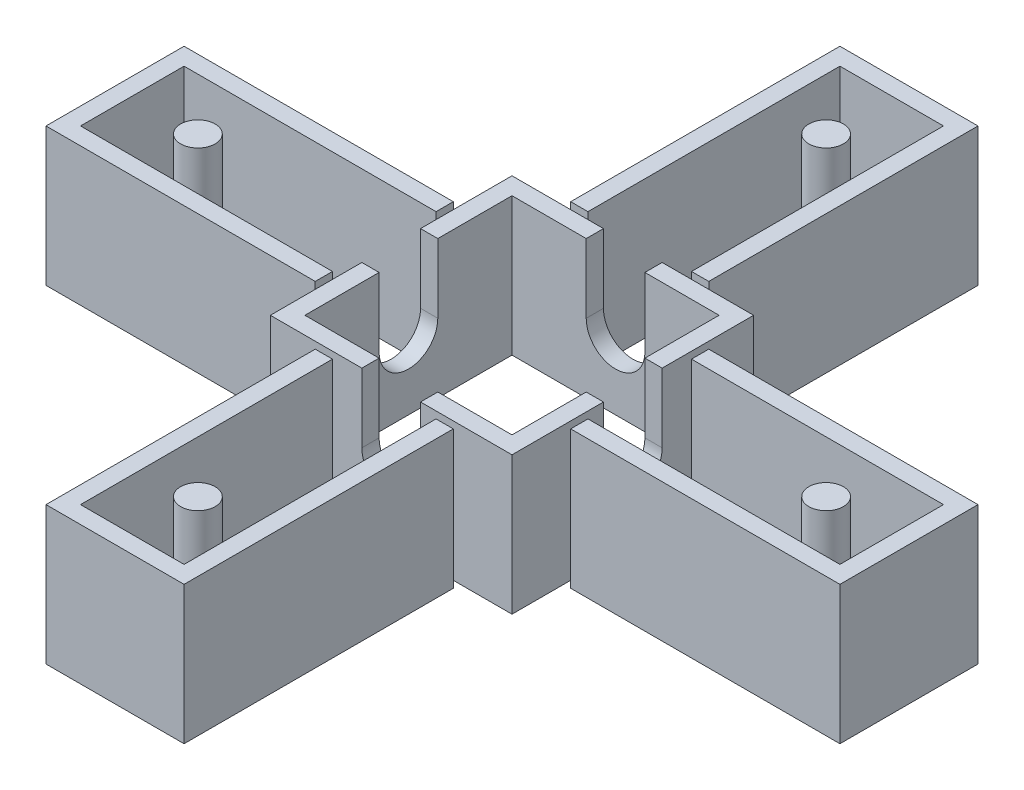
from build123d import *

# Parameters (mm, degrees)
SKETCH1_W           = 35
SKETCH1_H           = 35
SKETCH1_W_2         = 30
SKETCH1_H_2         = 30
BOSS_EXTRUDE1_DEPTH = 20
CUT_EXTRUDE1_DEPTH  = 2.5
CIRPATTERN1_COUNT   = 4
BOSS_EXTRUDE2_DEPTH = 20
SKETCH6_W           = 5
SKETCH6_H           = 3
BOSS_EXTRUDE3_DEPTH = 12
SKETCH7_R           = 2.5
BOSS_EXTRUDE4_DEPTH = 17
CIRPATTERN6_COUNT   = 4
SKETCH8_W           = 2.5
SKETCH8_H           = 1
SKETCH8_W_2         = 1
SKETCH8_H_2         = 2.5
CUT_EXTRUDE4_DEPTH  = 21


with BuildPart() as part:
    # Sketch1 → Boss-Extrude1 (new body)
    with BuildSketch(Plane(origin=(0, 0, 0), x_dir=(1, 0, 0), z_dir=(0, 1, 0))):
        Rectangle(SKETCH1_W, SKETCH1_H)
        Rectangle(SKETCH1_W_2, SKETCH1_H_2, mode=Mode.SUBTRACT)
    extrude(amount=BOSS_EXTRUDE1_DEPTH)

    # Sketch2 → Cut-Extrude1 (cut)
    with BuildSketch(Plane.ZY.offset(17.5)):
        with BuildLine():
            Line((-4.25, 10), (-4.25, 20))
            Line((-4.25, 20), (4.25, 20))
            Line((4.25, 20), (4.25, 10))
            ThreePointArc((4.25, 10), (0, 5.75), (-4.25, 10))
        make_face()
    cut_extrude1 = extrude(amount=-CUT_EXTRUDE1_DEPTH, mode=Mode.SUBTRACT)

    # CirPattern1: Cut-Extrude1 ×4 about axis
    cirpattern1_axis = Axis((0, 0, 0), (0, 1, 0))
    for i in range(1, CIRPATTERN1_COUNT):
        add(cut_extrude1.rotate(cirpattern1_axis, i * 360 / CIRPATTERN1_COUNT), mode=Mode.SUBTRACT)

    # Sketch5 → Boss-Extrude2 (add)
    with BuildSketch(Plane(origin=(0, 0, 0), x_dir=(1, 0, 0), z_dir=(0, 1, 0))):
        Polygon((7.5, 17.5), (7.5, 55), (-7.5, 55), (-7.5, 17.5), (-10, 17.5), (-10, 57.5), (10, 57.5), (10, 17.5), align=None)
    boss_extrude2 = extrude(amount=BOSS_EXTRUDE2_DEPTH)

    # Sketch6 → Boss-Extrude3 (add)
    with BuildSketch(Plane.XY.offset(-55)):
        with Locations((0, 1.5)):
            Rectangle(SKETCH6_W, SKETCH6_H)
    boss_extrude3 = extrude(amount=BOSS_EXTRUDE3_DEPTH)

    # Sketch7 → Boss-Extrude4 (add)
    with BuildSketch(Plane(origin=(0, 3, 0), x_dir=(1, 0, 0), z_dir=(0, 1, 0))):
        with Locations((0, 45.5)):
            Circle(SKETCH7_R)
    boss_extrude4 = extrude(amount=BOSS_EXTRUDE4_DEPTH)

    # CirPattern6: Boss-Extrude2, Boss-Extrude3, Boss-Extrude4 ×4 about axis
    cirpattern6_axis = Axis((0, 0, 0), (0, 1, 0))
    for i in range(1, CIRPATTERN6_COUNT):
        add(boss_extrude2.rotate(cirpattern6_axis, i * 360 / CIRPATTERN6_COUNT))
        add(boss_extrude3.rotate(cirpattern6_axis, i * 360 / CIRPATTERN6_COUNT))
        add(boss_extrude4.rotate(cirpattern6_axis, i * 360 / CIRPATTERN6_COUNT))

    # Sketch8 → Cut-Extrude4 (cut, through all)
    with BuildSketch(Plane(origin=(0, 20, 0), x_dir=(1, 0, 0), z_dir=(0, 1, 0))):
        with Locations((8.75, 18)):
            Rectangle(SKETCH8_W, SKETCH8_H)
        with Locations((-8.75, 18)):
            Rectangle(SKETCH8_W, SKETCH8_H)
        with Locations((18, -8.75)):
            Rectangle(SKETCH8_W_2, SKETCH8_H_2)
        with Locations((18, 8.75)):
            Rectangle(SKETCH8_W_2, SKETCH8_H_2)
        with Locations((-8.75, -18)):
            Rectangle(SKETCH8_W, SKETCH8_H)
        with Locations((8.75, -18)):
            Rectangle(SKETCH8_W, SKETCH8_H)
        with Locations((-18, 8.75)):
            Rectangle(SKETCH8_W_2, SKETCH8_H_2)
        with Locations((-18, -8.75)):
            Rectangle(SKETCH8_W_2, SKETCH8_H_2)
    extrude(amount=-CUT_EXTRUDE4_DEPTH, mode=Mode.SUBTRACT)


solid = part.part
